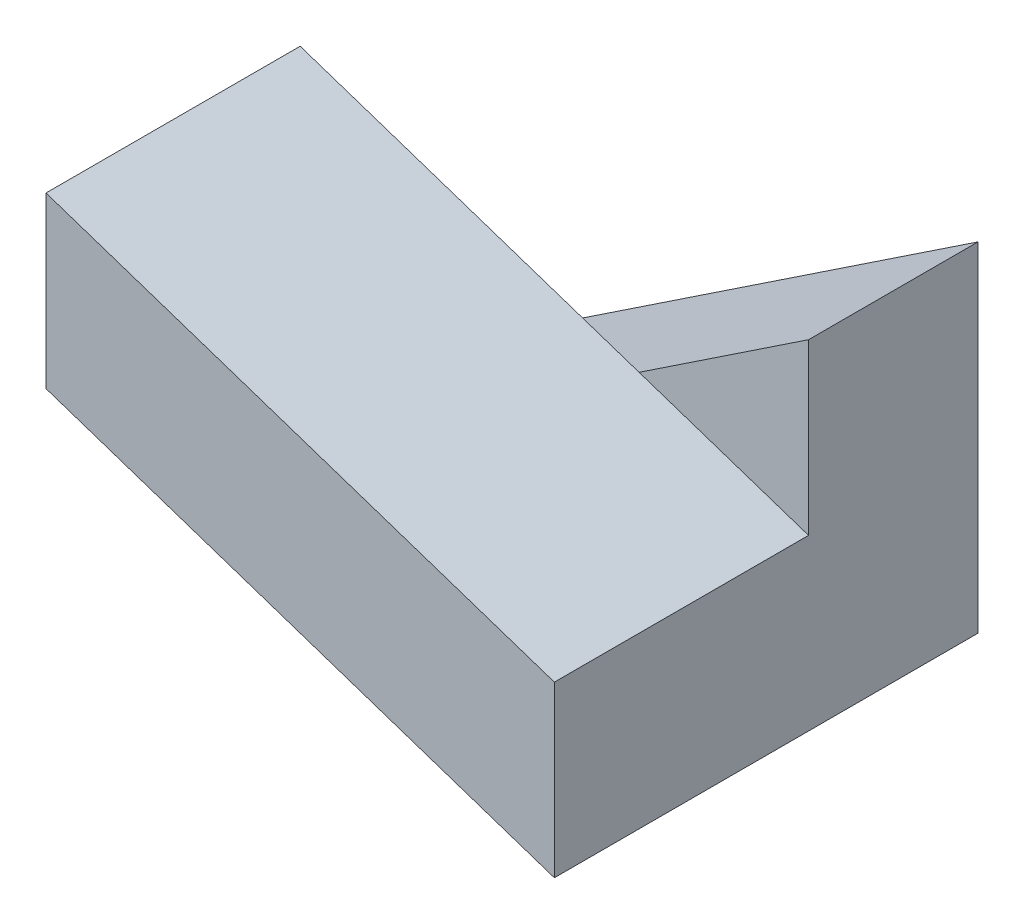
from build123d import *

# Parameters (mm, degrees)
BOSS_EXTRUDE1_DEPTH = 10
BOSS_EXTRUDE2_DEPTH = 15


with BuildPart() as part:
    # Sketch1 → Boss-Extrude1 (new body)
    with BuildSketch(Plane.XY):
        Polygon((-30, 0), (0, 0), (0, 20), align=None)
    extrude(amount=BOSS_EXTRUDE1_DEPTH)

    # Sketch2 → Boss-Extrude2 (add)
    with BuildSketch(Plane.XY.offset(10)):
        Polygon((0, 10), (0, 0), (-30, 10), (-30, 20), align=None)
    extrude(amount=BOSS_EXTRUDE2_DEPTH)


solid = part.part
